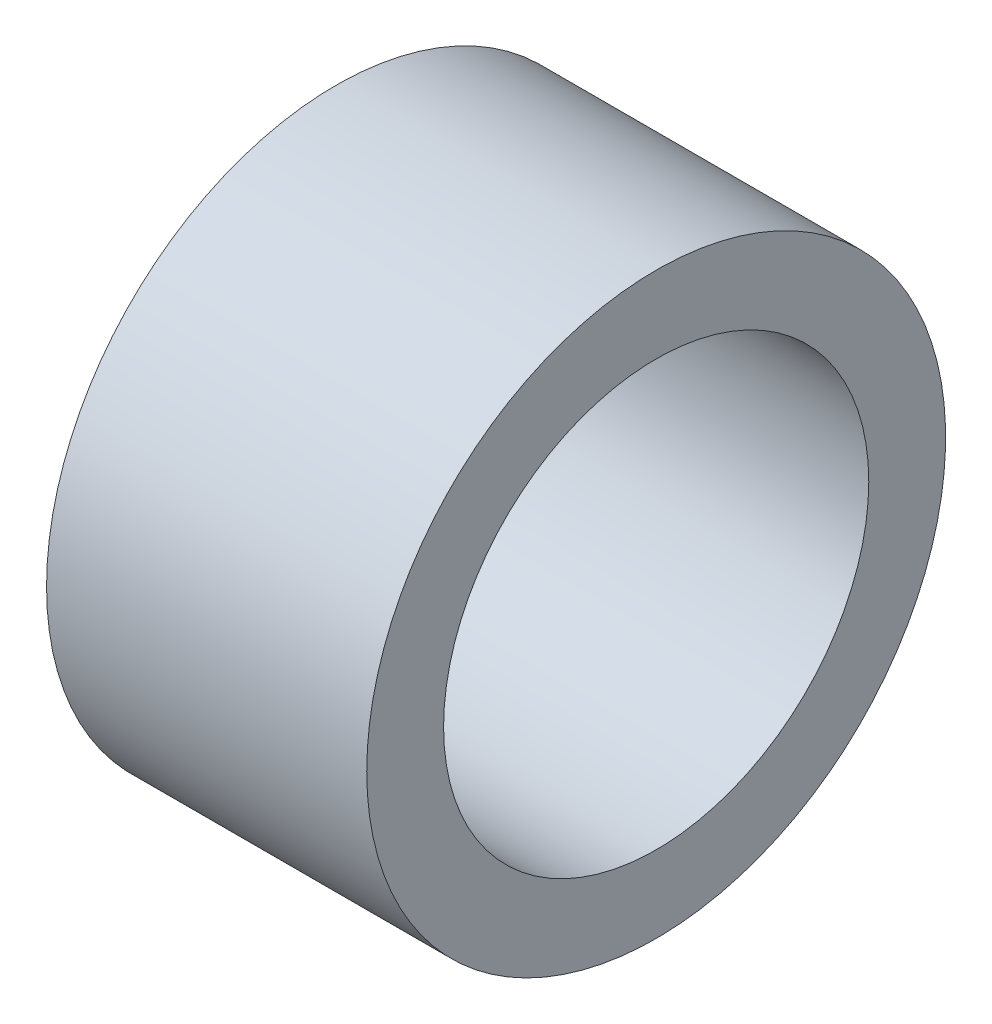
from build123d import *

# Parameters (mm, degrees)
SKETCH1_W = 6.25
SKETCH1_H = 1.5


with BuildPart() as part:
    # Sketch1 → Revolve1 (revolve)
    with BuildSketch(Plane(origin=(0, 0, 0), x_dir=(1, 0, 0), z_dir=(0, 1, 0))):
        with Locations((3.125, -4.9)):
            Rectangle(SKETCH1_W, SKETCH1_H)
    revolve(axis=Axis((0, 0, 0), (1, 0, 0)))


solid = part.part
